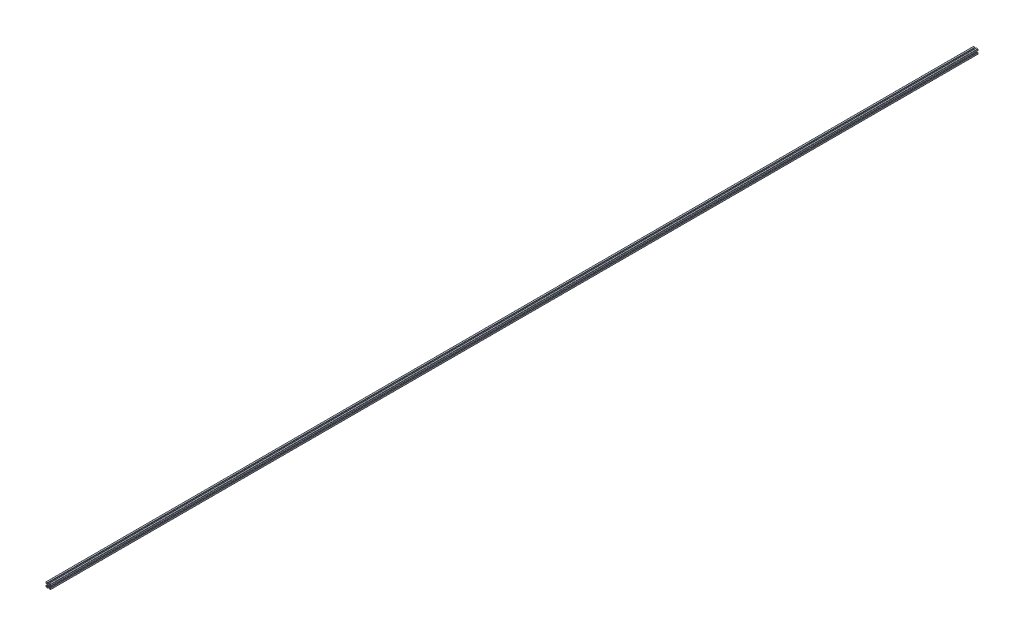
from build123d import *

# Parameters (mm, degrees)
SKETCH_2_R      = 2.0999999
EXTRUDE_1_DEPTH = 4000


with BuildPart() as part:
    # ｽｹｯﾁ2 → 押し出し1 (new body)
    with BuildSketch(Plane.XY):
        with BuildLine():
            Line((10, 9), (10, 3.3))
            ThreePointArc((10, 3.3), (9.912132034, 3.087867966), (9.7, 3))
            Line((9.7, 3), (8, 3))
            Line((8, 3), (8, 6))
            Line((8, 6), (7.06, 6))
            Line((7.06, 6), (4, 2.94))
            Line((4, 2.94), (4, 0.3))
            Line((4, 0.3), (3.7, 0))
            Line((3.7, 0), (4, -0.3))
            Line((4, -0.3), (4, -2.94))
            Line((4, -2.94), (7.06, -6))
            Line((7.06, -6), (8, -6))
            Line((8, -6), (8, -3))
            Line((8, -3), (9.7, -3))
            ThreePointArc((9.7, -3), (9.912132034, -3.087867966), (10, -3.3))
            Line((10, -3.3), (10, -9))
            ThreePointArc((10, -9), (9.707106781, -9.707106781), (9, -10))
            Line((9, -10), (3.3, -10))
            ThreePointArc((3.3, -10), (3.087867966, -9.912132034), (3, -9.7))
            Line((3, -9.7), (3, -8.000001421))
            Line((3, -8.000001421), (6, -8.000001421))
            Line((6, -8.000001421), (6, -7.060001421))
            Line((6, -7.060001421), (2.939906298, -3.999907719))
            Line((2.939906298, -3.999907719), (0.3, -3.999907719))
            Line((0.3, -3.999907719), (0, -3.699907719))
            Line((0, -3.699907719), (-0.3, -3.999907719))
            Line((-0.3, -3.999907719), (-2.939906298, -3.999907719))
            Line((-2.939906298, -3.999907719), (-6, -7.060001421))
            Line((-6, -7.060001421), (-6, -8.000001421))
            Line((-6, -8.000001421), (-3, -8.000001421))
            Line((-3, -8.000001421), (-3, -9.7))
            ThreePointArc((-3, -9.7), (-3.087867966, -9.912132034), (-3.3, -10))
            Line((-3.3, -10), (-9, -10))
            ThreePointArc((-9, -10), (-9.707106781, -9.707106781), (-10, -9))
            Line((-10, -9), (-10, -3.3))
            ThreePointArc((-10, -3.3), (-9.912132034, -3.087867966), (-9.7, -3))
            Line((-9.7, -3), (-8, -3))
            Line((-8, -3), (-8, -6))
            Line((-8, -6), (-7.06, -6))
            Line((-7.06, -6), (-4, -2.94))
            Line((-4, -2.94), (-4, -0.3))
            Line((-4, -0.3), (-3.7, 0))
            Line((-3.7, 0), (-4, 0.3))
            Line((-4, 0.3), (-4, 2.94))
            Line((-4, 2.94), (-7.06, 6))
            Line((-7.06, 6), (-8, 6))
            Line((-8, 6), (-8, 3))
            Line((-8, 3), (-9.7, 3))
            ThreePointArc((-9.7, 3), (-9.912132034, 3.087867966), (-10, 3.3))
            Line((-10, 3.3), (-10, 9))
            ThreePointArc((-10, 9), (-9.707106781, 9.707106781), (-9, 10))
            Line((-9, 10), (-3.3, 10))
            ThreePointArc((-3.3, 10), (-3.087867966, 9.912132034), (-3, 9.7))
            Line((-3, 9.7), (-3, 8.000001421))
            Line((-3, 8.000001421), (-6, 8.000001421))
            Line((-6, 8.000001421), (-6, 7.060001421))
            Line((-6, 7.060001421), (-2.939906298, 3.999907719))
            Line((-2.939906298, 3.999907719), (-0.3, 3.999907719))
            Line((-0.3, 3.999907719), (0, 3.699907719))
            Line((0, 3.699907719), (0.3, 3.999907719))
            Line((0.3, 3.999907719), (2.939906298, 3.999907719))
            Line((2.939906298, 3.999907719), (6, 7.060001421))
            Line((6, 7.060001421), (6, 8.000001421))
            Line((6, 8.000001421), (3, 8.000001421))
            Line((3, 8.000001421), (3, 9.7))
            ThreePointArc((3, 9.7), (3.087867966, 9.912132034), (3.3, 10))
            Line((3.3, 10), (9, 10))
            ThreePointArc((9, 10), (9.707106781, 9.707106781), (10, 9))
        make_face()
        Circle(SKETCH_2_R, mode=Mode.SUBTRACT)
    extrude(amount=EXTRUDE_1_DEPTH)


solid = part.part
